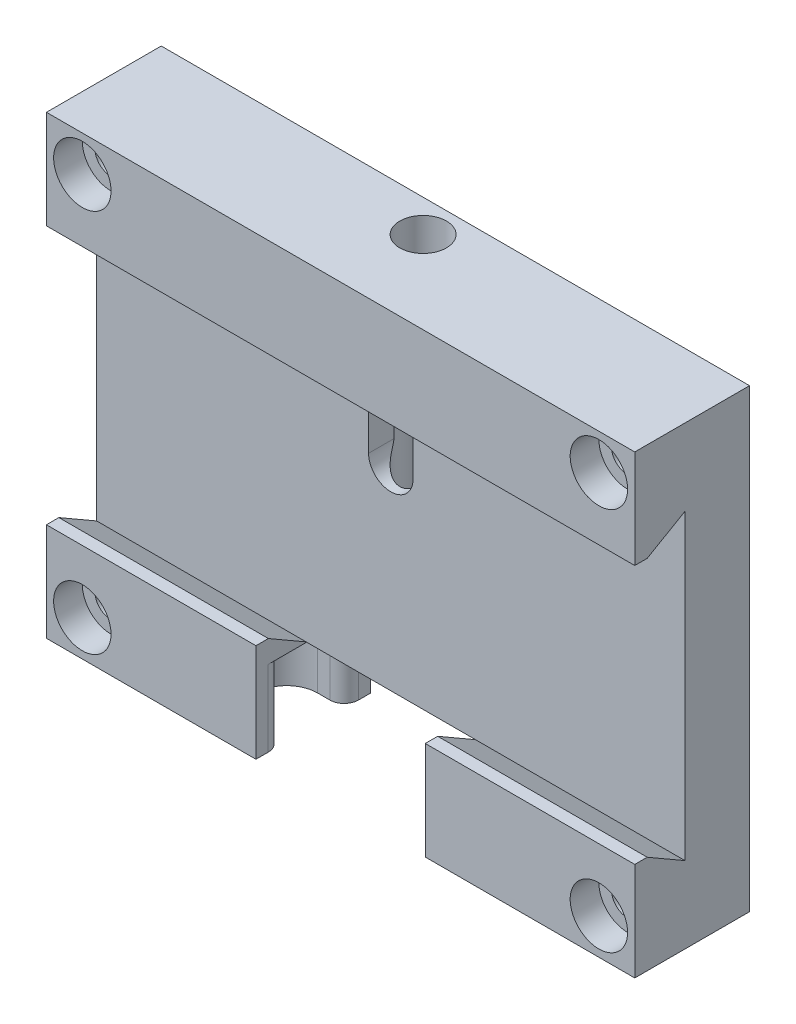
from build123d import *

# Parameters (mm, degrees)
SKETCH_1_W                  = 82
SKETCH_1_H                  = 63.5
EXTRUDE_1_DEPTH             = 16
CUT_EXTRUDE_1_DEPTH         = 83
SKETCH_15_W                 = 23.6
SKETCH_15_H                 = 14.711451884
CUT_EXTRUDE_4_DEPTH         = 7
SKETCH_16_W                 = 23.6
SKETCH_16_H                 = 10.67
CUT_EXTRUDE_5_DEPTH         = 9
SKETCH_17_R                 = 2.5
CUT_EXTRUDE_6_DEPTH         = 8
M4X0_72_D                   = 3.3
M4X0_72_DEPTH               = 10
M4X0_72_TIP                 = 0.991420021
CUT_EXTRUDE_7_DEPTH         = 4
SKETCH_26_R                 = 3.25
CUT_EXTRUDE_8_DEPTH         = 38
HOLE_WIZARD_M41_D           = 4.5
HOLE_WIZARD_M41_CBORE_D     = 8
HOLE_WIZARD_M41_CBORE_DEPTH = 4
CHAMFER_2_SIZE              = 1
CHAMFER_2_SIZE2             = 2
CHAMFER_2_PART_2_SIZE       = 1
CHAMFER_2_PART_2_SIZE2      = 2
CHAMFER_2_PART_3_SIZE       = 1
CHAMFER_2_PART_3_SIZE2      = 2
CUT_EXTRUDE_12_DEPTH        = 10.6
FILLET_1_R                  = 2


with BuildPart() as part:
    # Эскиз1 → Бобышка-Вытянуть1 (new body)
    with BuildSketch(Plane.XY):
        with Locations((41, -31.75)):
            Rectangle(SKETCH_1_W, SKETCH_1_H)
    extrude(amount=EXTRUDE_1_DEPTH)

    # Эскиз2 → Вырез-Вытянуть1 (cut, through all)
    with BuildSketch(Plane.ZY):
        Polygon((9, -10.67), (16, -14.711451884), (16, -48.788548116), (9, -52.83), align=None)
    extrude(amount=-CUT_EXTRUDE_1_DEPTH, mode=Mode.SUBTRACT)

    # Эскиз15 → Вырез-Вытянуть4 (cut)
    with BuildSketch(Plane.XY.offset(16)):
        with Locations((41, -56.144274058)):
            Rectangle(SKETCH_15_W, SKETCH_15_H)
    extrude(amount=-CUT_EXTRUDE_4_DEPTH, mode=Mode.SUBTRACT)

    # Эскиз16 → Вырез-Вытянуть5 (cut)
    with BuildSketch(Plane.XY.offset(9)):
        with Locations((41, -58.165)):
            Rectangle(SKETCH_16_W, SKETCH_16_H)
    extrude(amount=-CUT_EXTRUDE_5_DEPTH, mode=Mode.SUBTRACT)

    # Эскиз17 → Вырез-Вытянуть6 (cut)
    with BuildSketch(Plane.XZ.offset(52.83)):
        with Locations((33.5, 5)):
            Circle(SKETCH_17_R)
        with Locations((48.5, 5)):
            Circle(SKETCH_17_R)
    extrude(amount=-CUT_EXTRUDE_6_DEPTH, mode=Mode.SUBTRACT)

    # Отверстие обработанное метчиком M4x0.72
    with Locations(Plane(origin=(0, -52.83, 0), x_dir=(-1, 0, 0), z_dir=(0, -1, 0))):
        with Locations((-41, -5)):
            Hole(M4X0_72_D / 2, depth=M4X0_72_DEPTH)
            with Locations((0, 0, -(M4X0_72_DEPTH + M4X0_72_TIP / 2))):  # 118° drill point
                Cone(0, M4X0_72_D / 2, M4X0_72_TIP, mode=Mode.SUBTRACT)

    # Эскиз25 → Вырез-Вытянуть7 (cut)
    with BuildSketch(Plane.XY.offset(9)):
        with BuildLine():
            Line((44.1, -18.711451884), (44.1, -25.711451884))
            ThreePointArc((44.1, -25.711451884), (41, -28.811451884), (37.9, -25.711451884))
            Line((37.9, -25.711451884), (37.9, -18.711451884))
            ThreePointArc((37.9, -18.711451884), (41, -15.611451884), (44.1, -18.711451884))
        make_face()
    extrude(amount=-CUT_EXTRUDE_7_DEPTH, mode=Mode.SUBTRACT)

    # Эскиз26 → Вырез-Вытянуть8 (cut)
    with BuildSketch(Plane(origin=(0, 0, 0), x_dir=(1, 0, 0), z_dir=(0, 1, 0))):
        with Locations((41, -4.5)):
            Circle(SKETCH_26_R)
    extrude(amount=-CUT_EXTRUDE_8_DEPTH, mode=Mode.SUBTRACT)

    # Цековка для винта с внутренним шестигранником M41 (through all)
    with Locations(Plane(origin=(30.759227947, 26.793365177, 16), x_dir=(-1, 0, 0), z_dir=(0, 0, 1))):
        with Locations((-46.240772053, 31.793365177), (-46.240772053, 85.293365177), (25.759227947, 85.293365177), (25.759227947, 31.793365177)):
            CounterBoreHole(HOLE_WIZARD_M41_D / 2, HOLE_WIZARD_M41_CBORE_D / 2, HOLE_WIZARD_M41_CBORE_DEPTH)

    # Фаска2
    chamfer_2_edges = [part.edges().sort_by_distance(p)[0] for p in [
        (41, -14.711451884, 16),
    ]]
    chamfer_2_side = [part.faces().sort_by_distance(p)[0] for p in [
        (41, -7.569889145, 16),
    ]]
    chamfer(chamfer_2_edges, length=CHAMFER_2_SIZE, length2=CHAMFER_2_SIZE2, reference=chamfer_2_side[0])

    # Фаска2 part 2
    chamfer_2_part_2_edges = [part.edges().sort_by_distance(p)[0] for p in [
        (67.4, -48.788548116, 16),
    ]]
    chamfer_2_part_2_side = [part.faces().sort_by_distance(p)[0] for p in [
        (66.127821531, -55.832096576, 16),
    ]]
    chamfer(chamfer_2_part_2_edges, length=CHAMFER_2_PART_2_SIZE, length2=CHAMFER_2_PART_2_SIZE2, reference=chamfer_2_part_2_side[0])

    # Фаска2 part 3
    chamfer_2_part_3_edges = [part.edges().sort_by_distance(p)[0] for p in [
        (14.6, -48.788548116, 16),
    ]]
    chamfer_2_part_3_side = [part.faces().sort_by_distance(p)[0] for p in [
        (15.872178469, -55.832096576, 16),
    ]]
    chamfer(chamfer_2_part_3_edges, length=CHAMFER_2_PART_3_SIZE, length2=CHAMFER_2_PART_3_SIZE2, reference=chamfer_2_part_3_side[0])

    # Эскиз32 → Вырез-Вытянуть12 (cut)
    with BuildSketch(Plane.XZ.offset(63.5)):
        with BuildLine():
            Line((29.5, 12.3), (25.5, 12.3))
            ThreePointArc((25.5, 12.3), (21.2, 8), (25.5, 3.7))
            Line((25.5, 3.7), (29.5, 3.7))
            Line((29.5, 3.7), (29.5, 12.3))
        make_face()
        with BuildLine():
            Line((52.5, 3.7), (56.5, 3.7))
            ThreePointArc((56.5, 3.7), (60.8, 8), (56.5, 12.3))
            Line((56.5, 12.3), (52.5, 12.3))
            Line((52.5, 12.3), (52.5, 3.7))
        make_face()
    extrude(amount=-CUT_EXTRUDE_12_DEPTH, mode=Mode.SUBTRACT)

    # Скругление1
    fillet_1_edges = [part.edges().sort_by_distance(p)[0] for p in [
        (29.2, -58.2, 12.3),
        (29.2, -58.2, 3.7),
        (52.8, -58.2, 3.7),
        (52.8, -58.2, 12.3),
    ]]
    fillet(fillet_1_edges, radius=FILLET_1_R)


solid = part.part
